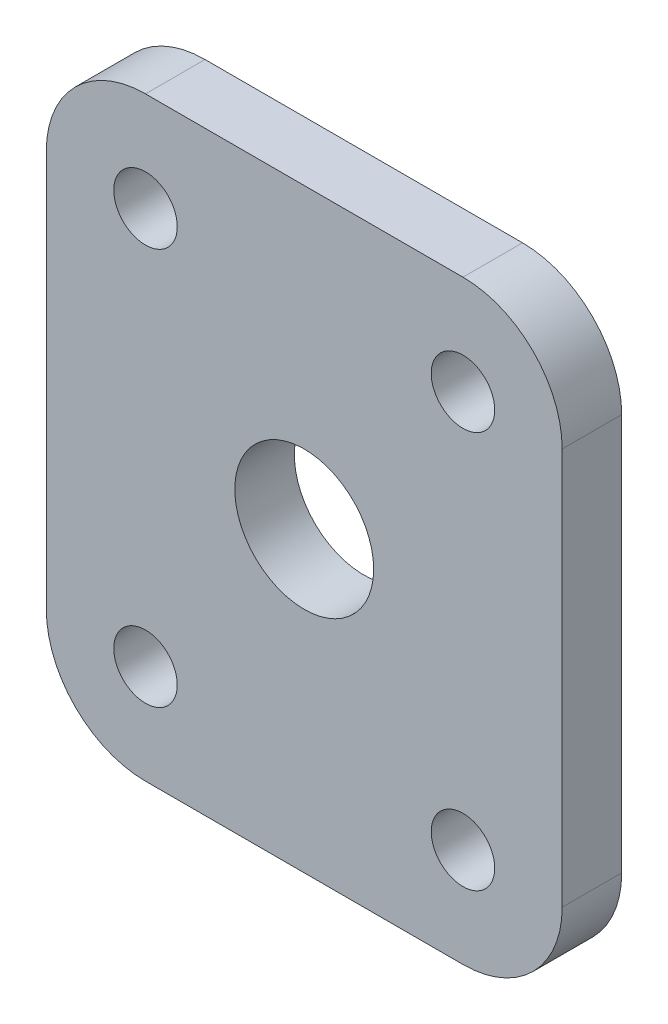
from build123d import *

# Parameters (mm, degrees)
ESBO_O1_W                = 26
ESBO_O1_H                = 30
ESBO_O1_R                = 3.5
ESBO_O1_R_2              = 1.6
RESSALTO_EXTRUS_O1_DEPTH = 3
FILETE1_R                = 5


with BuildPart() as part:
    # Esboço1 → Ressalto-extrusão1 (new body)
    with BuildSketch(Plane.XY):
        Rectangle(ESBO_O1_W, ESBO_O1_H)
        Circle(ESBO_O1_R, mode=Mode.SUBTRACT)
        with Locations((8, 10)):
            Circle(ESBO_O1_R_2, mode=Mode.SUBTRACT)
        with Locations((-8, 10)):
            Circle(ESBO_O1_R_2, mode=Mode.SUBTRACT)
        with Locations((8, -10)):
            Circle(ESBO_O1_R_2, mode=Mode.SUBTRACT)
        with Locations((-8, -10)):
            Circle(ESBO_O1_R_2, mode=Mode.SUBTRACT)
    extrude(amount=RESSALTO_EXTRUS_O1_DEPTH)

    # Filete1
    filete1_edges = [part.edges().sort_by_distance(p)[0] for p in [
        (-13, -15, 1.5),
        (-13, 15, 1.5),
        (13, 15, 1.5),
        (13, -15, 1.5),
    ]]
    fillet(filete1_edges, radius=FILETE1_R)


solid = part.part
